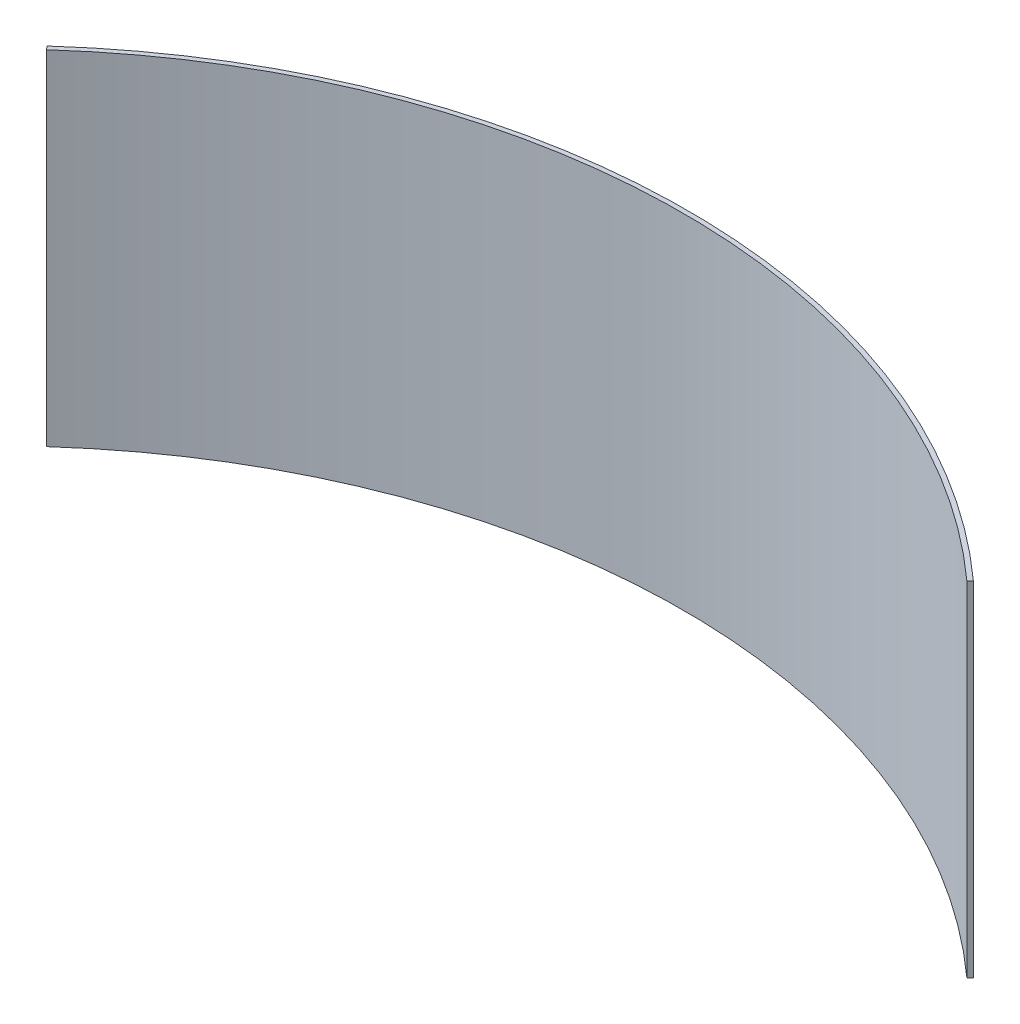
from build123d import *

# Parameters (mm, degrees)
BOSS_EXTRUDE1_DEPTH = 7.5


with BuildPart() as part:
    # Sketch1 → Boss-Extrude1 (new body, symmetric)
    with BuildSketch(Plane(origin=(0, 0, 0), x_dir=(1, 0, 0), z_dir=(0, 1, 0))):
        with BuildLine():
            Line((-20.214365176, 22.437010508), (-20.080495208, 22.288421035))
            ThreePointArc((-20.080495208, 22.288421035), (0, 30), (20.080495208, 22.288421035))
            Line((20.080495208, 22.288421035), (20.214365176, 22.437010508))
            ThreePointArc((20.214365176, 22.437010508), (0, 30.2), (-20.214365176, 22.437010508))
        make_face()
    extrude(amount=BOSS_EXTRUDE1_DEPTH, both=True)


solid = part.part
